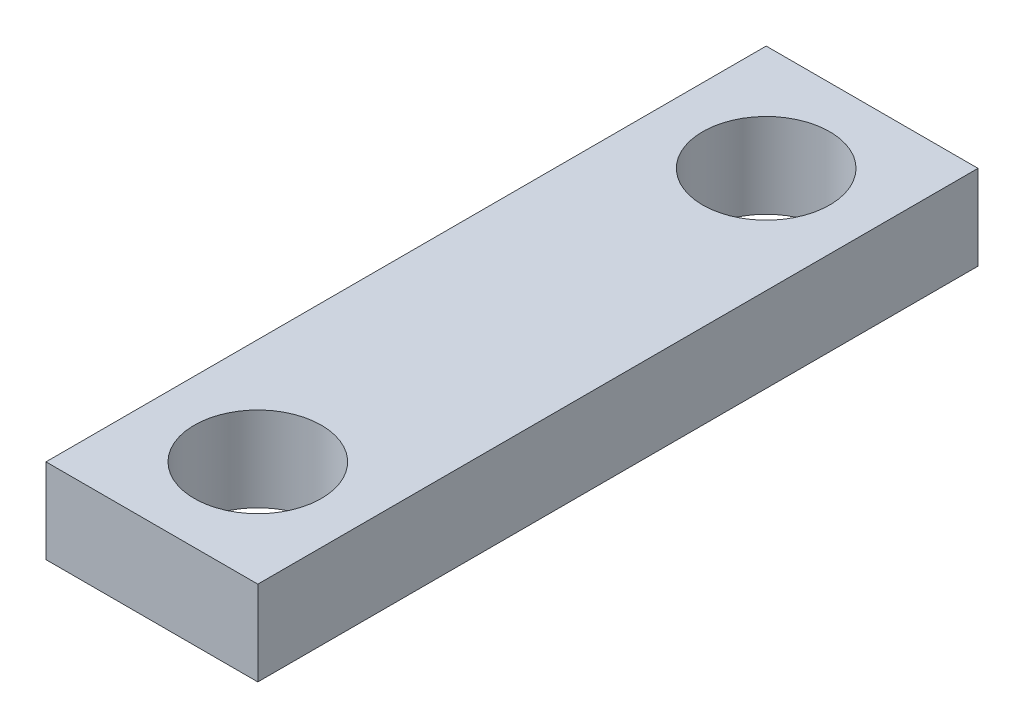
from build123d import *

# Parameters (mm, degrees)
SKETCH1_W           = 6.35
SKETCH1_H           = 21.59
SKETCH1_R           = 1.905
BOSS_EXTRUDE1_DEPTH = 2.54


with BuildPart() as part:
    # Sketch1 → Boss-Extrude1 (new body)
    with BuildSketch(Plane(origin=(0, 0, 0), x_dir=(1, 0, 0), z_dir=(0, 1, 0))):
        Rectangle(SKETCH1_W, SKETCH1_H)
        with Locations((0, 7.62)):
            Circle(SKETCH1_R, mode=Mode.SUBTRACT)
        with Locations((0, -7.62)):
            Circle(SKETCH1_R, mode=Mode.SUBTRACT)
    extrude(amount=BOSS_EXTRUDE1_DEPTH)


solid = part.part
